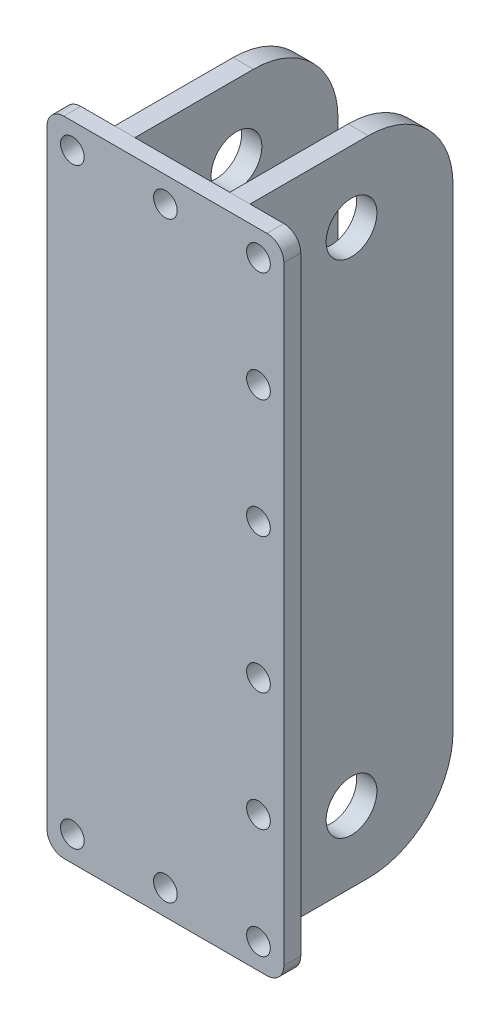
from build123d import *

# Parameters (mm, degrees)
EXTRUDE_1_DEPTH     = 10
CUT_EXTRUDE_1_REACH = 12
SKETCH_2_R          = 7
SKETCH_3_W          = 12
SKETCH_3_H          = 380
EXTRUDE_2_DEPTH     = 120
EXTRUDE_2_2_DEPTH   = 120
FILLET_1_R          = 50
FILLET_2_R          = 50
SKETCH_4_R          = 15
CUT_EXTRUDE_2_DEPTH = 12
SKETCH_5_R          = 15
CUT_EXTRUDE_3_DEPTH = 12


with BuildPart() as part:
    # 草图1 → 凸台-拉伸1 (new body)
    with BuildSketch(Plane.XY):
        with BuildLine():
            Line((10, 0), (130, 0))
            ThreePointArc((130, 0), (137.071067812, 2.928932188), (140, 10))
            Line((140, 10), (140, 370))
            ThreePointArc((140, 370), (137.071067812, 377.071067812), (130, 380))
            Line((130, 380), (10, 380))
            ThreePointArc((10, 380), (2.928932188, 377.071067812), (0, 370))
            Line((0, 370), (0, 10))
            ThreePointArc((0, 10), (2.928932188, 2.928932188), (10, 0))
        make_face()
    extrude(amount=EXTRUDE_1_DEPTH)

    # 草图2 → 切除-拉伸1 (cut, up to next)
    with BuildSketch(Plane.XY.offset(10), mode=Mode.PRIVATE) as cut_extrude_1_sk1:
        with Locations((15, 365)):
            Circle(SKETCH_2_R)
    cut_extrude_1_tool1 = extrude(cut_extrude_1_sk1.sketch, amount=-CUT_EXTRUDE_1_REACH, mode=Mode.PRIVATE) & part.part
    add(cut_extrude_1_tool1.solids().sort_by_distance((15, 365, 10))[0], mode=Mode.SUBTRACT)
    # 草图2 → 切除-拉伸1 (cut, up to next)
    with BuildSketch(Plane.XY.offset(10), mode=Mode.PRIVATE) as cut_extrude_1_sk2:
        with Locations((125, 365)):
            Circle(SKETCH_2_R)
    cut_extrude_1_tool2 = extrude(cut_extrude_1_sk2.sketch, amount=-CUT_EXTRUDE_1_REACH, mode=Mode.PRIVATE) & part.part
    add(cut_extrude_1_tool2.solids().sort_by_distance((125, 365, 10))[0], mode=Mode.SUBTRACT)
    # 草图2 → 切除-拉伸1 (cut, up to next)
    with BuildSketch(Plane.XY.offset(10), mode=Mode.PRIVATE) as cut_extrude_1_sk3:
        with Locations((15, 15)):
            Circle(SKETCH_2_R)
    cut_extrude_1_tool3 = extrude(cut_extrude_1_sk3.sketch, amount=-CUT_EXTRUDE_1_REACH, mode=Mode.PRIVATE) & part.part
    add(cut_extrude_1_tool3.solids().sort_by_distance((15, 15, 10))[0], mode=Mode.SUBTRACT)
    # 草图2 → 切除-拉伸1 (cut, up to next)
    with BuildSketch(Plane.XY.offset(10), mode=Mode.PRIVATE) as cut_extrude_1_sk4:
        with Locations((125, 15)):
            Circle(SKETCH_2_R)
    cut_extrude_1_tool4 = extrude(cut_extrude_1_sk4.sketch, amount=-CUT_EXTRUDE_1_REACH, mode=Mode.PRIVATE) & part.part
    add(cut_extrude_1_tool4.solids().sort_by_distance((125, 15, 10))[0], mode=Mode.SUBTRACT)
    # 草图2 → 切除-拉伸1 (cut, up to next)
    with BuildSketch(Plane.XY.offset(10), mode=Mode.PRIVATE) as cut_extrude_1_sk5:
        with Locations((70, 365)):
            Circle(SKETCH_2_R)
    cut_extrude_1_tool5 = extrude(cut_extrude_1_sk5.sketch, amount=-CUT_EXTRUDE_1_REACH, mode=Mode.PRIVATE) & part.part
    add(cut_extrude_1_tool5.solids().sort_by_distance((70, 365, 10))[0], mode=Mode.SUBTRACT)
    # 草图2 → 切除-拉伸1 (cut, up to next)
    with BuildSketch(Plane.XY.offset(10), mode=Mode.PRIVATE) as cut_extrude_1_sk6:
        with Locations((70, 15)):
            Circle(SKETCH_2_R)
    cut_extrude_1_tool6 = extrude(cut_extrude_1_sk6.sketch, amount=-CUT_EXTRUDE_1_REACH, mode=Mode.PRIVATE) & part.part
    add(cut_extrude_1_tool6.solids().sort_by_distance((70, 15, 10))[0], mode=Mode.SUBTRACT)
    # 草图2 → 切除-拉伸1 (cut, up to next)
    with BuildSketch(Plane.XY.offset(10), mode=Mode.PRIVATE) as cut_extrude_1_sk7:
        with Locations((125, 300)):
            Circle(SKETCH_2_R)
    cut_extrude_1_tool7 = extrude(cut_extrude_1_sk7.sketch, amount=-CUT_EXTRUDE_1_REACH, mode=Mode.PRIVATE) & part.part
    add(cut_extrude_1_tool7.solids().sort_by_distance((125, 300, 10))[0], mode=Mode.SUBTRACT)
    # 草图2 → 切除-拉伸1 (cut, up to next)
    with BuildSketch(Plane.XY.offset(10), mode=Mode.PRIVATE) as cut_extrude_1_sk8:
        with Locations((125, 80)):
            Circle(SKETCH_2_R)
    cut_extrude_1_tool8 = extrude(cut_extrude_1_sk8.sketch, amount=-CUT_EXTRUDE_1_REACH, mode=Mode.PRIVATE) & part.part
    add(cut_extrude_1_tool8.solids().sort_by_distance((125, 80, 10))[0], mode=Mode.SUBTRACT)
    # 草图2 → 切除-拉伸1 (cut, up to next)
    with BuildSketch(Plane.XY.offset(10), mode=Mode.PRIVATE) as cut_extrude_1_sk9:
        with Locations((125, 230)):
            Circle(SKETCH_2_R)
    cut_extrude_1_tool9 = extrude(cut_extrude_1_sk9.sketch, amount=-CUT_EXTRUDE_1_REACH, mode=Mode.PRIVATE) & part.part
    add(cut_extrude_1_tool9.solids().sort_by_distance((125, 230, 10))[0], mode=Mode.SUBTRACT)
    # 草图2 → 切除-拉伸1 (cut, up to next)
    with BuildSketch(Plane.XY.offset(10), mode=Mode.PRIVATE) as cut_extrude_1_sk10:
        with Locations((125, 150)):
            Circle(SKETCH_2_R)
    cut_extrude_1_tool10 = extrude(cut_extrude_1_sk10.sketch, amount=-CUT_EXTRUDE_1_REACH, mode=Mode.PRIVATE) & part.part
    add(cut_extrude_1_tool10.solids().sort_by_distance((125, 150, 10))[0], mode=Mode.SUBTRACT)


with BuildPart() as body_2:
    # 草图3 → 凸台-拉伸2 (new body)
    with BuildSketch(Plane(origin=(0, 0, 0), x_dir=(-1, 0, 0), z_dir=(0, 0, -1))):
        with Locations((-104, 190)):
            Rectangle(SKETCH_3_W, SKETCH_3_H)
    extrude(amount=EXTRUDE_2_DEPTH)

    # 圆角1
    fillet_1_edges = [body_2.edges().sort_by_distance(p)[0] for p in [
        (104, 380, -120),
        (104, 0, -120),
    ]]
    fillet(fillet_1_edges, radius=FILLET_1_R)

    # 草图4 → 切除-拉伸2 (cut)
    with BuildSketch(Plane(origin=(110, 0, 0), x_dir=(0, 0, -1), z_dir=(1, 0, 0))):
        with Locations((60, 338)):
            Circle(SKETCH_4_R)
        with Locations((60, 42)):
            Circle(SKETCH_4_R)
    extrude(amount=-CUT_EXTRUDE_2_DEPTH, mode=Mode.SUBTRACT)


with BuildPart() as body_3:
    # 草图3 → Extrude 2 2 (new body)
    with BuildSketch(Plane(origin=(0, 0, 0), x_dir=(-1, 0, 0), z_dir=(0, 0, -1))):
        with Locations((-36, 190)):
            Rectangle(SKETCH_3_W, SKETCH_3_H)
    extrude(amount=EXTRUDE_2_2_DEPTH)

    # 圆角2
    fillet_2_edges = [body_3.edges().sort_by_distance(p)[0] for p in [
        (36, 380, -120),
        (36, 0, -120),
    ]]
    fillet(fillet_2_edges, radius=FILLET_2_R)

    # 草图5 → 切除-拉伸3 (cut)
    with BuildSketch(Plane.ZY.offset(-30)):
        with Locations((-60, 338)):
            Circle(SKETCH_5_R)
        with Locations((-60, 42)):
            Circle(SKETCH_5_R)
    extrude(amount=-CUT_EXTRUDE_3_DEPTH, mode=Mode.SUBTRACT)


solid = Compound([part.part, body_2.part, body_3.part])
